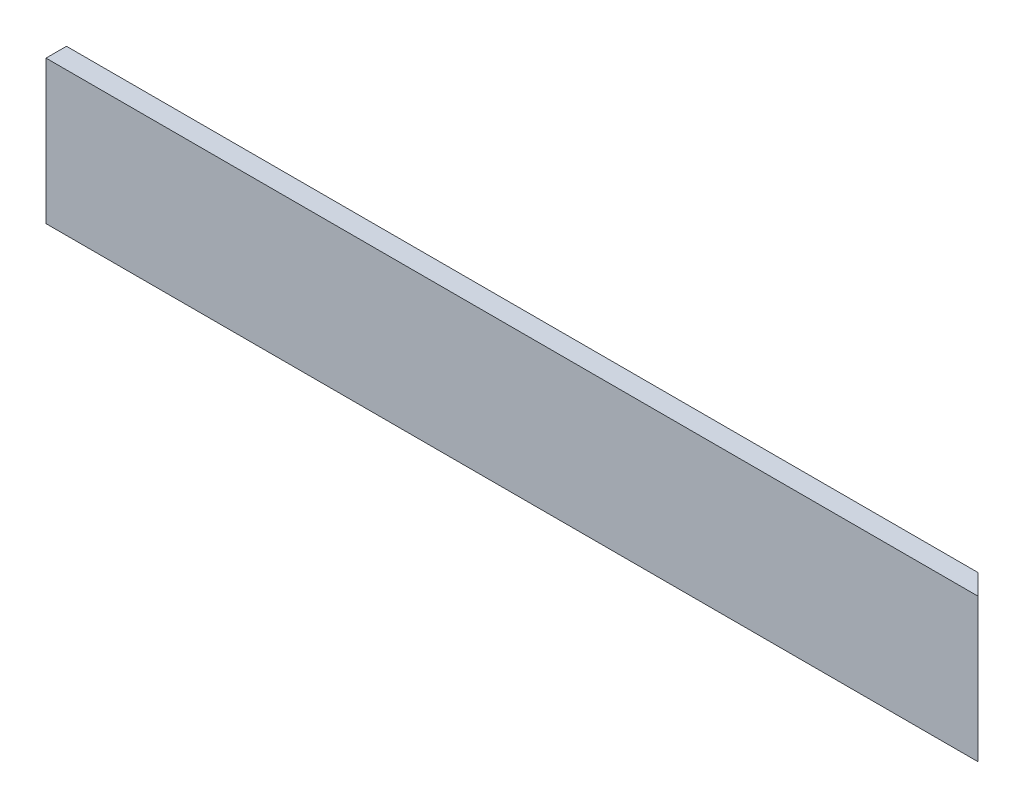
from build123d import *

# Parameters (mm, degrees)
SKETCH1_W           = 577.85
SKETCH1_H           = 88.9
BOSS_EXTRUDE1_DEPTH = 12.7
CUT_EXTRUDE1_DEPTH  = 89.9


with BuildPart() as part:
    # Sketch1 → Boss-Extrude1 (new body)
    with BuildSketch(Plane.XY):
        with Locations((107.959870466, -22.313834197)):
            Rectangle(SKETCH1_W, SKETCH1_H)
    extrude(amount=BOSS_EXTRUDE1_DEPTH)

    # Sketch2 → Cut-Extrude1 (cut, through all)
    with BuildSketch(Plane(origin=(0, 22.136165803, 0), x_dir=(1, 0, 0), z_dir=(0, 1, 0))):
        Polygon((396.884870466, -12.7), (384.184870466, 0), (396.884870466, 0), align=None)
    extrude(amount=-CUT_EXTRUDE1_DEPTH, mode=Mode.SUBTRACT)


solid = part.part
